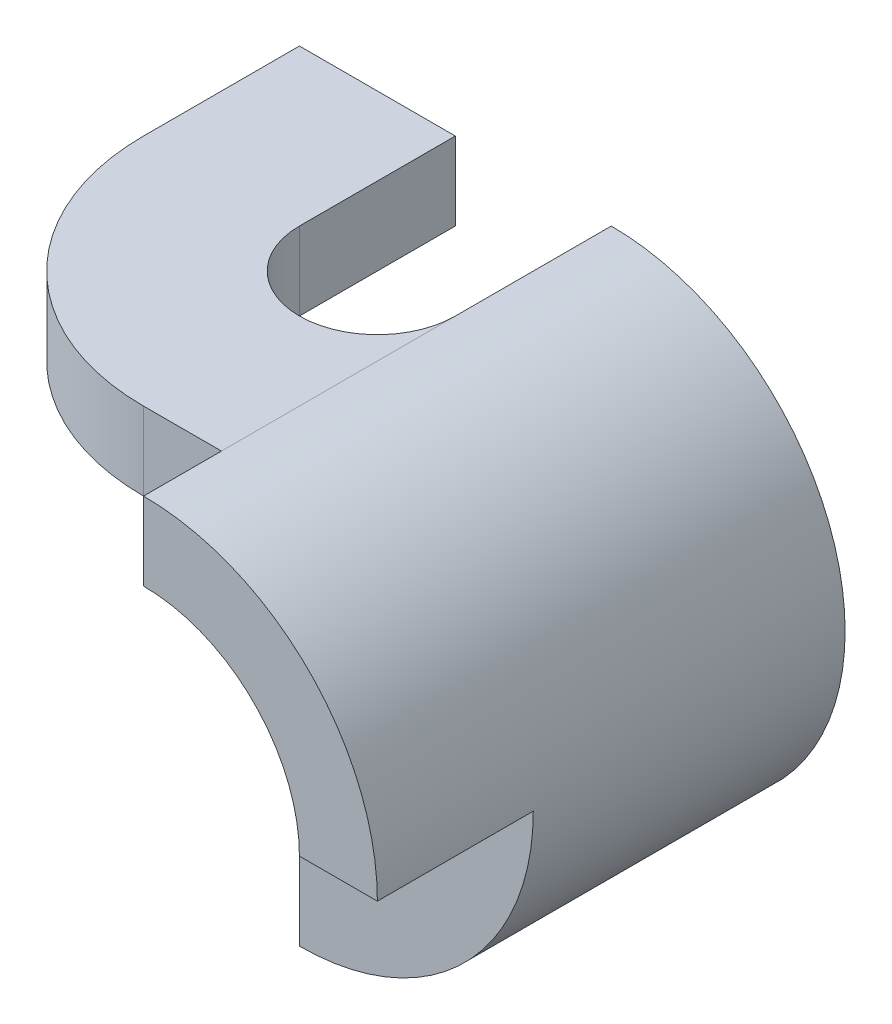
from build123d import *

# Parameters (mm, degrees)
BOSS_EXTRUDE1_DEPTH = 6
CUT_EXTRUDE1_DEPTH  = 2
CUT_EXTRUDE2_DEPTH  = 2
CUT_EXTRUDE3_DEPTH  = 2
CUT_EXTRUDE4_DEPTH  = 3


with BuildPart() as part:
    # Sketch1 → Boss-Extrude1 (new body)
    with BuildSketch(Plane.XY):
        with BuildLine():
            Line((0, 2), (-4, 2))
            Line((-4, 2), (-4, 3))
            Line((-4, 3), (0, 3))
            ThreePointArc((0, 3), (3, 0), (0, -3))
            Line((0, -3), (-1, -3))
            Line((-1, -3), (-1, -2))
            Line((-1, -2), (0, -2))
            ThreePointArc((0, -2), (2, 0), (0, 2))
        make_face()
    extrude(amount=BOSS_EXTRUDE1_DEPTH)

    # Sketch2 → Cut-Extrude1 (cut)
    with BuildSketch(Plane.XY.offset(6)):
        with BuildLine():
            Line((3, 0), (2, 0))
            ThreePointArc((2, 0), (1.414213562, -1.414213562), (0, -2))
            Line((0, -2), (0, -3))
            ThreePointArc((0, -3), (2.121320344, -2.121320344), (3, 0))
        make_face()
    extrude(amount=-CUT_EXTRUDE1_DEPTH, mode=Mode.SUBTRACT)

    # Sketch3 → Cut-Extrude2 (cut)
    with BuildSketch(Plane.XZ.offset(3)):
        Polygon((0, 4), (-1, 2), (-1, 6), (0, 6), align=None)
    extrude(amount=-CUT_EXTRUDE2_DEPTH, mode=Mode.SUBTRACT)

    # Sketch4 → Cut-Extrude3 (cut)
    with BuildSketch(Plane.XZ.offset(-2)):
        with BuildLine():
            Line((-1, 5), (0, 5))
            Line((0, 5), (0, 6))
            Line((0, 6), (-4, 6))
            Line((-4, 6), (-4, 2))
            ThreePointArc((-4, 2), (-3.121320344, 4.121320344), (-1, 5))
        make_face()
    extrude(amount=-CUT_EXTRUDE3_DEPTH, mode=Mode.SUBTRACT)

    # Sketch5 → Cut-Extrude4 (cut)
    with BuildSketch(Plane(origin=(0, 3, 0), x_dir=(1, 0, 0), z_dir=(0, 1, 0))):
        with BuildLine():
            Line((-2, 0), (-2, -2))
            ThreePointArc((-2, -2), (-1, -3), (0, -2))
            Line((0, -2), (0, 0))
            Line((0, 0), (-2, 0))
        make_face()
    extrude(amount=-CUT_EXTRUDE4_DEPTH, mode=Mode.SUBTRACT)


solid = part.part
